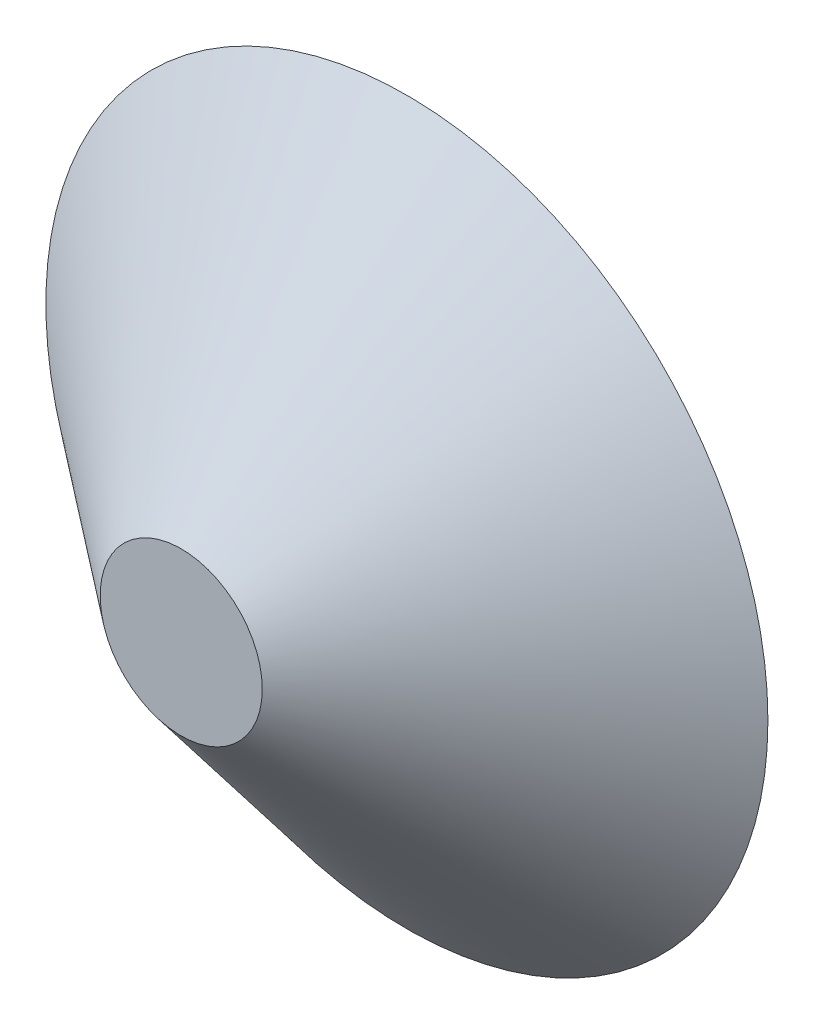
from build123d import *

# Parameters (mm, degrees)
SKETCH1_R           = 71.67
BOSS_EXTRUDE4_DEPTH = 44.8
BOSS_EXTRUDE4_TAPER = 51.13


with BuildPart() as part:
    # Sketch1 → Boss-Extrude4 (new body)
    with BuildSketch(Plane.XY):
        Circle(SKETCH1_R)
    extrude(amount=BOSS_EXTRUDE4_DEPTH, taper=BOSS_EXTRUDE4_TAPER)


solid = part.part
